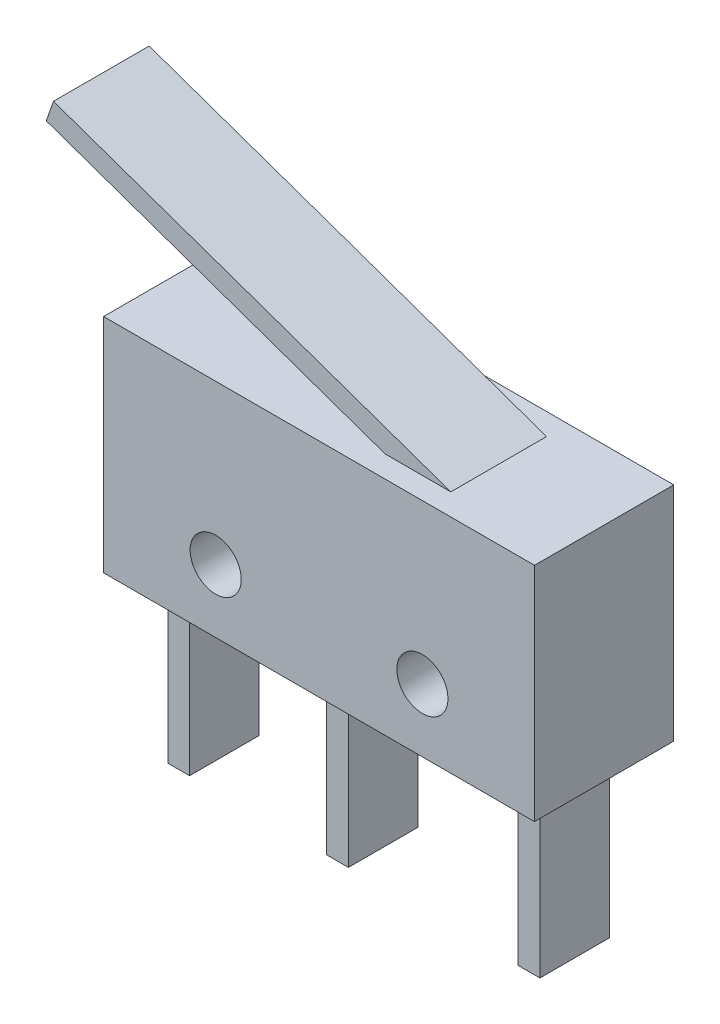
from build123d import *

# Parameters (mm, degrees)
SKETCH_1_W          = 19.8
SKETCH_1_H          = 10.2
EXTRUDE_1_DEPTH     = 6.4
SKETCH_2_R          = 1.175
CUT_EXTRUDE_1_DEPTH = 7.4
SKETCH_3_W          = 1
SKETCH_3_H          = 3.2
EXTRUDE_1_2_DEPTH   = 7.7
EXTRUDE_START       = -1
EXTRUDE_2_DEPTH     = 4.4


with BuildPart() as part:
    # 草图1 → Extrude 1 (new body)
    with BuildSketch(Plane.XY):
        Rectangle(SKETCH_1_W, SKETCH_1_H)
    extrude(amount=EXTRUDE_1_DEPTH)

    # 草图2 → 切除-拉伸1 (cut, through all)
    with BuildSketch(Plane(origin=(0, 0, 0), x_dir=(-1, 0, 0), z_dir=(0, 0, -1))):
        with Locations((-4.75, -2.2)):
            Circle(SKETCH_2_R)
        with Locations((4.75, -2.2)):
            Circle(SKETCH_2_R)
    extrude(amount=-CUT_EXTRUDE_1_DEPTH, mode=Mode.SUBTRACT)

    # 草图3 → Extrude 1 2 (add)
    with BuildSketch(Plane(origin=(0, -5.1, 0), x_dir=(-1, 0, 0), z_dir=(0, -1, 0))):
        with Locations((-8.05, -3.2)):
            Rectangle(SKETCH_3_W, SKETCH_3_H)
        with Locations((0.75, -3.2)):
            Rectangle(SKETCH_3_W, SKETCH_3_H)
        with Locations((8.05, -3.2)):
            Rectangle(SKETCH_3_W, SKETCH_3_H)
    extrude(amount=EXTRUDE_1_2_DEPTH)

    # 草图4 → 拉伸-薄壁2 (add)
    with BuildSketch(Plane(origin=(0, 0, 0), x_dir=(-1, 0, 0), z_dir=(0, 0, -1)).offset(EXTRUDE_START)):
        Polygon((-5.054923372, 5.1), (13.203386491, 11.514977847), (13.534867703, 10.571516026), (-4.723442161, 4.15653818), align=None)
    extrude(amount=-EXTRUDE_2_DEPTH)


solid = part.part
